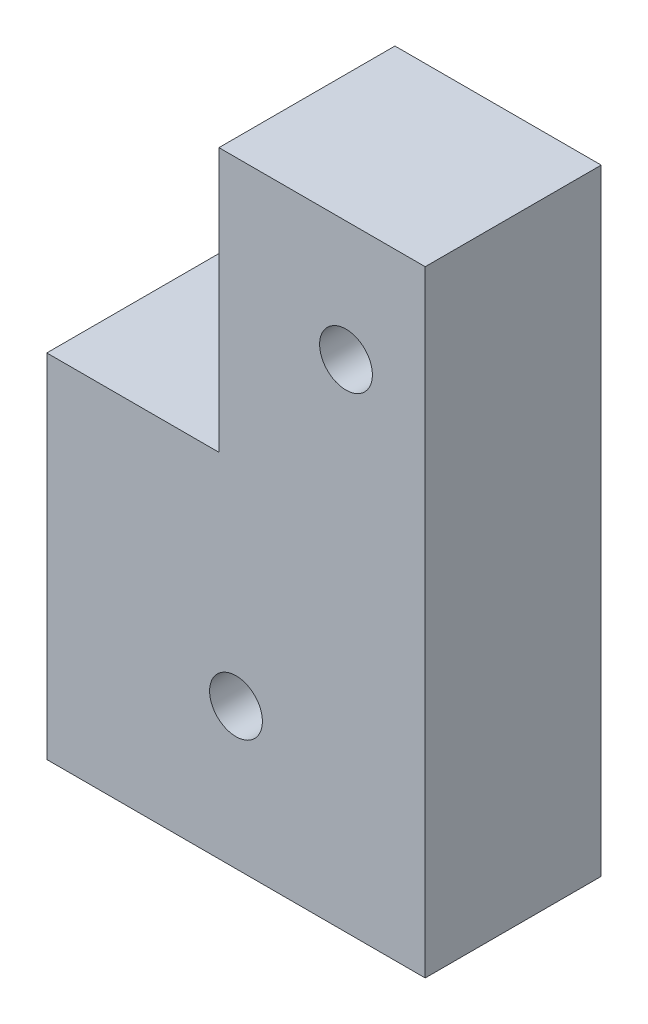
from build123d import *

# Parameters (mm, degrees)
EXTRUDE_1_DEPTH     = 10
SKETCH_2_W          = 10.780789019
SKETCH_2_H          = 10
CUT_EXTRUDE_1_DEPTH = 6
SKETCH_3_W          = 10
SKETCH_3_H          = 18.171763081
EXTRUDE_2_DEPTH     = 1
SKETCH_4_R          = 1.5
CUT_EXTRUDE_2_DEPTH = 11
SKETCH_5_W          = 11.719210981
SKETCH_5_H          = 10
CUT_EXTRUDE_3_DEPTH = 3.18


with BuildPart() as part:
    # 草图1 → 凸台-拉伸1 (new body)
    with BuildSketch(Plane.XY):
        Polygon((7.850374618, 8.603451253), (16.234951688, 8.603451253), (16.234951688, 16.628704923), (16.234951688, 20.775214334), (26.954162669, 20.775214334), (26.954162669, -17.403924352), (5.454162669, -17.403924352), (5.454162669, 8.603451253), align=None)
    extrude(amount=EXTRUDE_1_DEPTH)

    # 草图2 → 切除-拉伸1 (cut)
    with BuildSketch(Plane(origin=(0, 8.603451253, 0), x_dir=(1, 0, 0), z_dir=(0, 1, 0))):
        with Locations((10.844557179, -5)):
            Rectangle(SKETCH_2_W, SKETCH_2_H)
    extrude(amount=-CUT_EXTRUDE_1_DEPTH, mode=Mode.SUBTRACT)

    # 草图3 → 凸台-拉伸2 (add)
    with BuildSketch(Plane.ZY.offset(-16.234951688)):
        with Locations((5, 11.689332794)):
            Rectangle(SKETCH_3_W, SKETCH_3_H)
    extrude(amount=EXTRUDE_2_DEPTH)

    # 草图4 → 切除-拉伸2 (cut, through all)
    with BuildSketch(Plane.XY.offset(10)):
        with Locations((16.204162669, -9.403924352)):
            Circle(SKETCH_4_R)
        with Locations((22.454162669, 10.775214334)):
            Circle(SKETCH_4_R)
    extrude(amount=-CUT_EXTRUDE_2_DEPTH, mode=Mode.SUBTRACT)

    # 草图5 → 切除-拉伸3 (cut)
    with BuildSketch(Plane(origin=(0, 20.775214334, 0), x_dir=(1, 0, 0), z_dir=(0, 1, 0))):
        with Locations((21.094557179, -5)):
            Rectangle(SKETCH_5_W, SKETCH_5_H)
    extrude(amount=-CUT_EXTRUDE_3_DEPTH, mode=Mode.SUBTRACT)


solid = part.part
